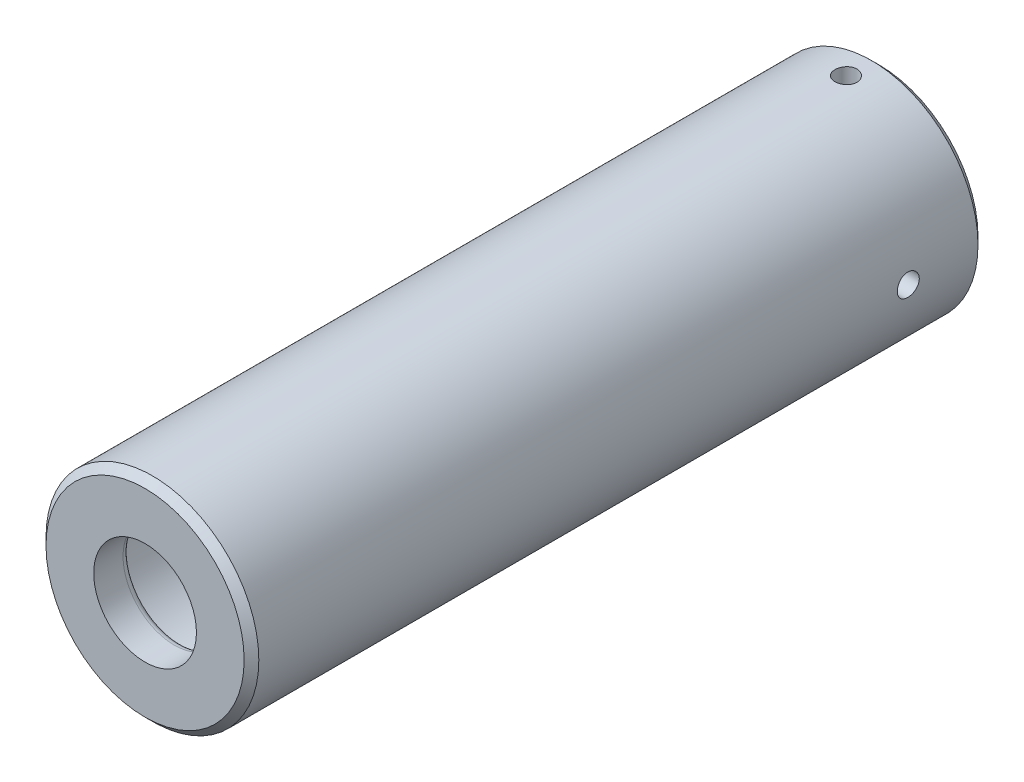
from build123d import *

# Parameters (mm, degrees)
ESQUISSE2_R                  = 1.5
ENL_V_MAT_EXTRU_1_DEPTH      = 15.5
ENL_V_MAT_EXTRU_1_DEPTH_BACK = 15.5
ESQUISSE3_R                  = 1.5
ENL_V_MAT_EXTRU_2_DEPTH      = 15.5000001
ENL_V_MAT_EXTRU_2_DEPTH_BACK = 15.5000001
CONG_1_R                     = 2
CONG_2_R                     = 1
CHANFREIN1_SIZE              = 1


with BuildPart() as part:
    # Esquisse1 → Révolution1 (revolve)
    with BuildSketch(Plane(origin=(0, 0, 0), x_dir=(0, 0, -1), z_dir=(1, 0, 0))):
        Polygon((-45, 11), (-45, 7), (-50, 7), (-50, 14.5), (50, 14.5), (50, 11), align=None)
    revolve(axis=Axis((0, 0, 50), (0, 0, -1)))

    # Esquisse2 → Enlèv. mat.-Extru.1 (cut, two sides)
    with BuildSketch(Plane(origin=(0, 0, 0), x_dir=(0, 0, -1), z_dir=(1, 0, 0))) as enl_v_mat_extru_1_sk:
        with Locations((39.5, 0)):
            Circle(ESQUISSE2_R)
    extrude(amount=ENL_V_MAT_EXTRU_1_DEPTH, mode=Mode.SUBTRACT)
    extrude(enl_v_mat_extru_1_sk.sketch, amount=-ENL_V_MAT_EXTRU_1_DEPTH_BACK, mode=Mode.SUBTRACT)

    # Esquisse3 → Enlèv. mat.-Extru.2 (cut, two sides)
    with BuildSketch(Plane(origin=(0, 0, 0), x_dir=(1, 0, 0), z_dir=(0, 1, 0))) as enl_v_mat_extru_2_sk:
        with Locations((0, 45.5)):
            Circle(ESQUISSE3_R)
    extrude(amount=ENL_V_MAT_EXTRU_2_DEPTH, mode=Mode.SUBTRACT)
    extrude(enl_v_mat_extru_2_sk.sketch, amount=-ENL_V_MAT_EXTRU_2_DEPTH_BACK, mode=Mode.SUBTRACT)

    # Congé1
    cong_1_edges = [part.edges().sort_by_distance(p)[0] for p in [
        (0, -11, 45),
    ]]
    fillet(cong_1_edges, radius=CONG_1_R)

    # Congé2
    cong_2_edges = [part.edges().sort_by_distance(p)[0] for p in [
        (0, -7, 45),
    ]]
    fillet(cong_2_edges, radius=CONG_2_R)

    # Chanfrein1
    chanfrein1_edges = [part.edges().sort_by_distance(p)[0] for p in [
        (0, -14.5, 50),
        (0, -14.5, -50),
    ]]
    chamfer(chanfrein1_edges, length=CHANFREIN1_SIZE)


solid = part.part
